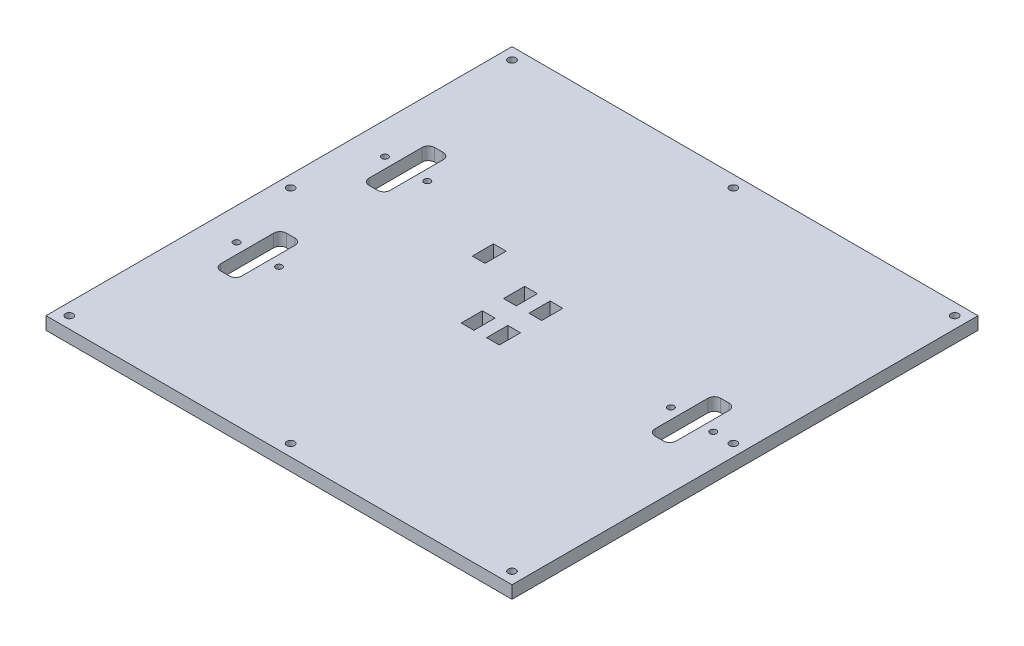
from build123d import *

# Parameters (mm, degrees)
SKETCH1_W                  = 220
SKETCH1_H                  = 220
BOSS_EXTRUDE1_DEPTH        = 6
SKETCH2_R                  = 1.5
SKETCH2_W                  = 10
SKETCH2_H                  = 31
CUT_EXTRUDE1_DEPTH         = 7
FILLET1_R                  = 3
SKETCH5_R                  = 1.5
SKETCH5_W                  = 10
SKETCH5_H                  = 31
CUT_EXTRUDE3_DEPTH         = 7
FILLET2_R                  = 3
SKETCH7_R                  = 1.5
SKETCH7_W                  = 10
SKETCH7_H                  = 31
CUT_EXTRUDE4_DEPTH         = 7
FILLET3_R                  = 3
F_3_6_3_6_DIAMETER_HOLE1_D = 3.6
SKETCH6_W                  = 10
SKETCH6_H                  = 6
CUT_EXTRUDE12_DEPTH        = 4
SKETCH61_W                 = 10
SKETCH61_H                 = 6
CUT_EXTRUDE13_DEPTH        = 4
SKETCH65_W                 = 10
SKETCH65_H                 = 6
CUT_EXTRUDE16_DEPTH        = 4
CUT_EXTRUDE16_DEPTH_BACK   = 4


with BuildPart() as part:
    # Sketch1 → Boss-Extrude1 (new body)
    with BuildSketch(Plane(origin=(0, 0, 0), x_dir=(1, 0, 0), z_dir=(0, 1, 0))):
        Rectangle(SKETCH1_W, SKETCH1_H)
    extrude(amount=BOSS_EXTRUDE1_DEPTH)

    # Sketch2 → Cut-Extrude1 (cut, through all)
    with BuildSketch(Plane(origin=(0, 6, 0), x_dir=(1, 0, 0), z_dir=(0, 1, 0))):
        with Locations((-95, 35)):
            Circle(SKETCH2_R)
        with Locations((-75, 35)):
            Circle(SKETCH2_R)
        with Locations((-85, 35)):
            Rectangle(SKETCH2_W, SKETCH2_H)
    extrude(amount=-CUT_EXTRUDE1_DEPTH, mode=Mode.SUBTRACT)

    # Fillet1
    fillet1_edges = [part.edges().sort_by_distance(p)[0] for p in [
        (-80, 3, -50.5),
        (-80, 3, -19.5),
        (-90, 3, -19.5),
        (-90, 3, -50.5),
    ]]
    fillet(fillet1_edges, radius=FILLET1_R)

    # Sketch5 → Cut-Extrude3 (cut, through all)
    with BuildSketch(Plane(origin=(45.510619452, 6, 46.414764374), x_dir=(1, 0, 0), z_dir=(0, 1, 0))):
        with Locations((-140.510619452, 11.414764374)):
            Circle(SKETCH5_R)
        with Locations((-120.510619452, 11.414764374)):
            Circle(SKETCH5_R)
        with Locations((-130.510619452, 11.414764374)):
            Rectangle(SKETCH5_W, SKETCH5_H)
    extrude(amount=-CUT_EXTRUDE3_DEPTH, mode=Mode.SUBTRACT)

    # Fillet2
    fillet2_edges = [part.edges().sort_by_distance(p)[0] for p in [
        (-80, 3, 19.5),
        (-80, 3, 50.5),
        (-90, 3, 50.5),
        (-90, 3, 19.5),
    ]]
    fillet(fillet2_edges, radius=FILLET2_R)

    # Sketch7 → Cut-Extrude4 (cut, through all)
    with BuildSketch(Plane(origin=(105.138163787, 6, 83.209962186), x_dir=(1, 0, 0), z_dir=(0, 1, 0))):
        with Locations((-30.138163787, 83.209962186)):
            Circle(SKETCH7_R)
        with Locations((-10.138163787, 83.209962186)):
            Circle(SKETCH7_R)
        with Locations((-20.138163787, 83.209962186)):
            Rectangle(SKETCH7_W, SKETCH7_H)
    extrude(amount=-CUT_EXTRUDE4_DEPTH, mode=Mode.SUBTRACT)

    # Fillet3
    fillet3_edges = [part.edges().sort_by_distance(p)[0] for p in [
        (90, 3, -15.5),
        (90, 3, 15.5),
        (80, 3, 15.5),
        (80, 3, -15.5),
    ]]
    fillet(fillet3_edges, radius=FILLET3_R)

    # Ø3.6 (3.6) Diameter Hole1 (through all)
    with Locations(Plane(origin=(0, 6, 0), x_dir=(1, 0, 0), z_dir=(0, 1, 0))):
        with Locations((-104.5, -104.5), (0, -104.5), (104.5, -104.5), (104.5, 0), (104.5, 104.5), (0, 104.5), (-104.5, 104.5), (-104.5, 0)):
            Hole(F_3_6_3_6_DIAMETER_HOLE1_D / 2)

    # Sketch6 → Cut-Extrude12 (cut, symmetric)
    with BuildSketch(Plane(origin=(-38, 3, -10.767778608), x_dir=(0, 0, 1), z_dir=(0, -1, 0))):
        with Locations((0.767778608, -44)):
            Rectangle(SKETCH6_W, SKETCH6_H)
    cut_extrude12 = extrude(amount=CUT_EXTRUDE12_DEPTH, both=True, mode=Mode.SUBTRACT)

    # Sketch61 → Cut-Extrude13 (cut, symmetric)
    with BuildSketch(Plane(origin=(-38, 3, 9.232221392), x_dir=(0, 0, 1), z_dir=(0, -1, 0))):
        with Locations((0.767778608, -44)):
            Rectangle(SKETCH61_W, SKETCH61_H)
    cut_extrude13 = extrude(amount=CUT_EXTRUDE13_DEPTH, both=True, mode=Mode.SUBTRACT)

    # Mirror1: Cut-Extrude12, Cut-Extrude13 across plane
    add(cut_extrude12.mirror(Plane(origin=(0, 0, 0), x_dir=(0, 0, 1), z_dir=(1, 0, 0))), mode=Mode.SUBTRACT)
    add(cut_extrude13.mirror(Plane(origin=(0, 0, 0), x_dir=(0, 0, 1), z_dir=(1, 0, 0))), mode=Mode.SUBTRACT)

    # Sketch65 → Cut-Extrude16 (cut, two sides)
    with BuildSketch(Plane(origin=(-74.75, 3, -20.767778608), x_dir=(0, 0, 1), z_dir=(0, -1, 0))) as cut_extrude16_sk:
        with Locations((0.767778608, -44)):
            Rectangle(SKETCH65_W, SKETCH65_H)
    extrude(amount=CUT_EXTRUDE16_DEPTH, mode=Mode.SUBTRACT)
    extrude(cut_extrude16_sk.sketch, amount=-CUT_EXTRUDE16_DEPTH_BACK, mode=Mode.SUBTRACT)


solid = part.part
